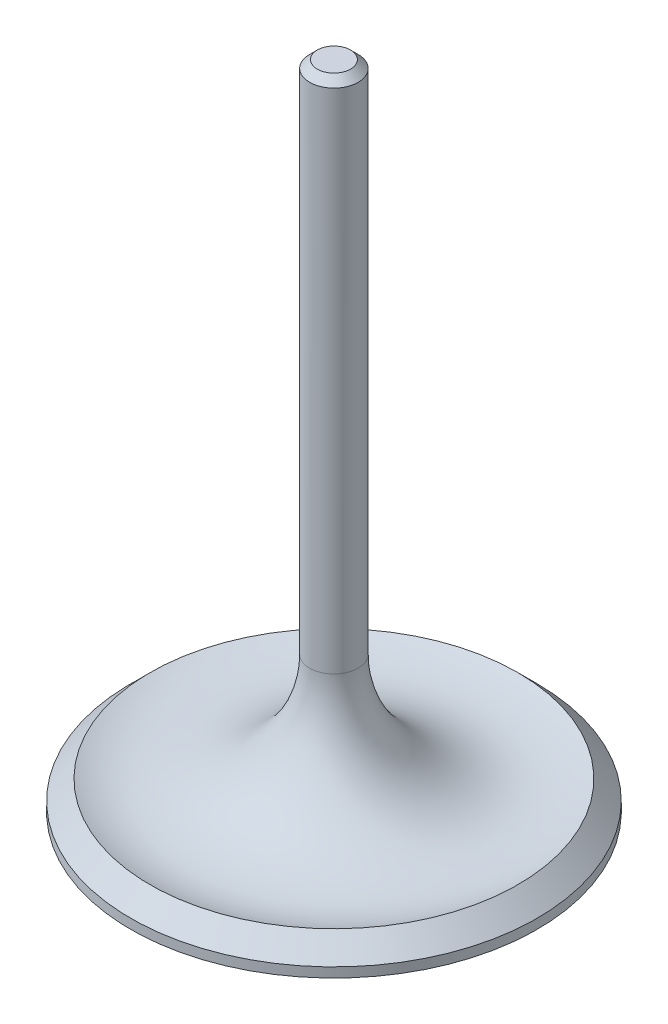
from build123d import *

# Parameters (mm, degrees)
CHAMFER1_SIZE = 1


with BuildPart() as part:
    # Sketch1 → Revolve1 (revolve)
    with BuildSketch(Plane.XY):
        with BuildLine():
            Line((0, 0), (0, 85.55))
            Line((0, 85.55), (3.18, 85.55))
            Line((3.18, 85.55), (3.18, 17.954698654))
            ThreePointArc((3.18, 17.954698654), (9.896609701, 5.315721242), (24.13, 3.81))
            Line((24.13, 3.81), (26.67, 1.27))
            Line((26.67, 1.27), (26.67, 0))
            Line((26.67, 0), (0, 0))
        make_face()
    revolve(axis=Axis((0, 0, 0), (0, 1, 0)))

    # Chamfer1
    chamfer1_edges = [part.edges().sort_by_distance(p)[0] for p in [
        (-3.18, 85.55, 0),
    ]]
    chamfer(chamfer1_edges, length=CHAMFER1_SIZE)


solid = part.part
